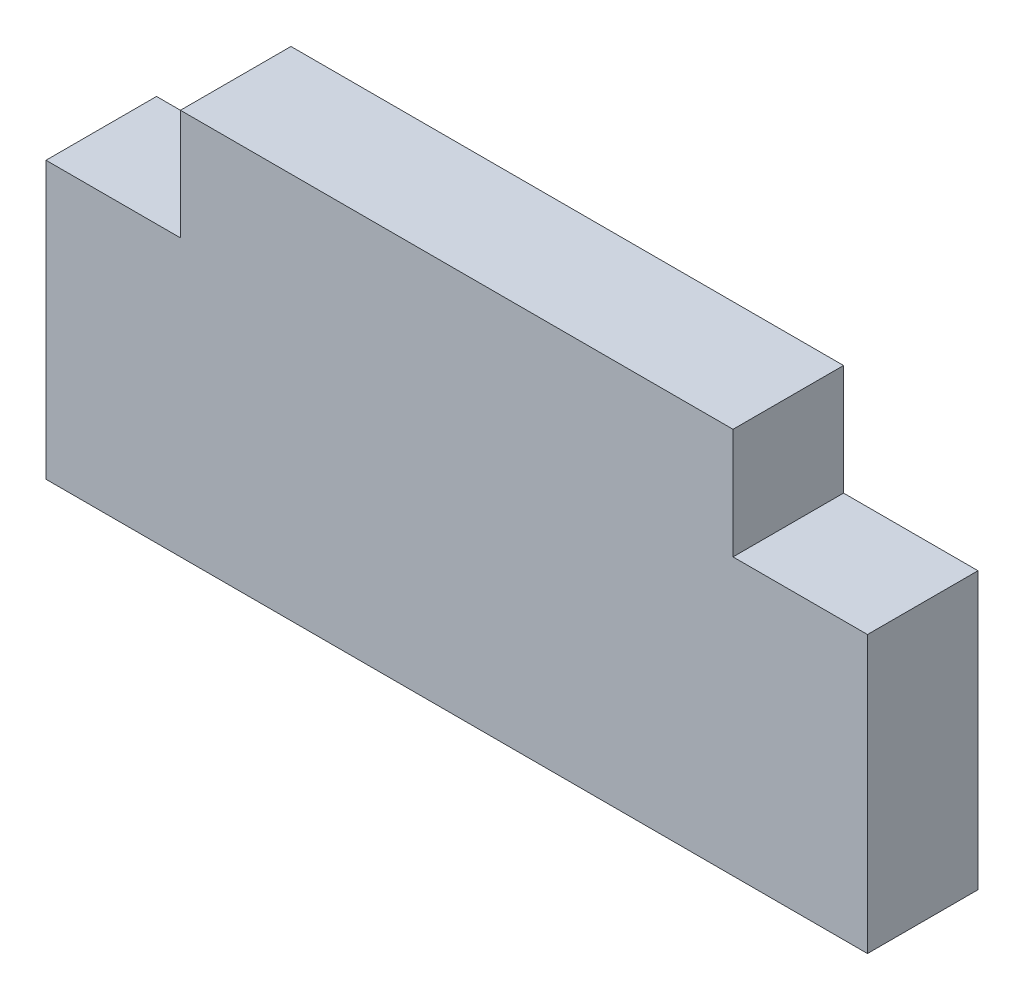
from build123d import *

# Parameters (mm, degrees)
SKETCH1_W           = 14.866068748
SKETCH1_H           = 2
BOSS_EXTRUDE1_DEPTH = 5
SKETCH2_W           = 10
SKETCH2_H           = 2
BOSS_EXTRUDE2_DEPTH = 2


with BuildPart() as part:
    # Sketch1 → Boss-Extrude1 (new body)
    with BuildSketch(Plane(origin=(0, 0, 0), x_dir=(1, 0, 0), z_dir=(0, 1, 0))):
        Rectangle(SKETCH1_W, SKETCH1_H)
    extrude(amount=BOSS_EXTRUDE1_DEPTH)

    # Sketch2 → Boss-Extrude2 (add)
    with BuildSketch(Plane(origin=(0, 5, 0), x_dir=(1, 0, 0), z_dir=(0, 1, 0))):
        Rectangle(SKETCH2_W, SKETCH2_H)
    extrude(amount=BOSS_EXTRUDE2_DEPTH)


solid = part.part
